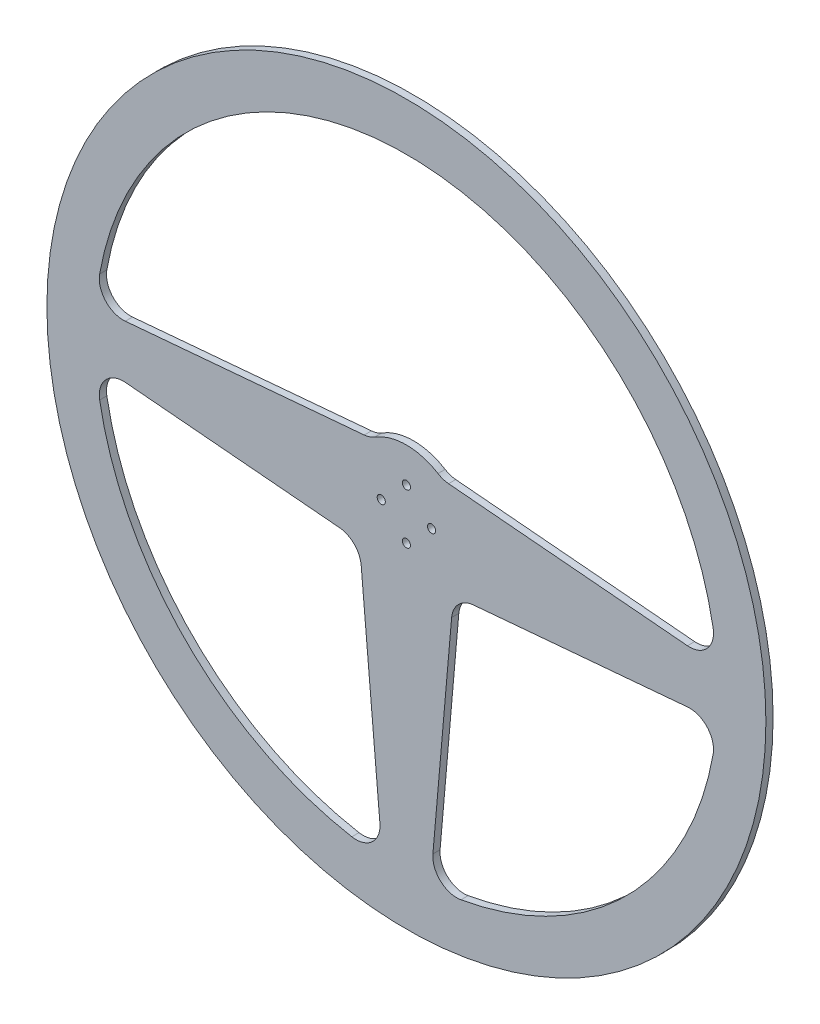
from build123d import *

# Parameters (mm, degrees)
CROQUIS1_R                   = 150
SALIENTE_EXTRUIR1_DEPTH      = 3
REDONDEO1_R                  = 10
TALADRO_DE_MARGEN_PARA_M31_D = 3.4


with BuildPart() as part:
    # Croquis1 → Saliente-Extruir1 (new body)
    with BuildSketch(Plane.XY):
        Circle(CROQUIS1_R)
        with BuildLine():
            Line((9.972316505, -129.616946822), (19.597749078, -19.597749078))
            Line((19.597749078, -19.597749078), (129.616946822, -9.972316505))
            ThreePointArc((129.616946822, -9.972316505), (91.923881554, -91.923881554), (9.972316505, -129.616946822))
        make_face(mode=Mode.SUBTRACT)
        with BuildLine():
            Line((129.616946822, 9.972316505), (15, 20))
            ThreePointArc((15, 20), (0, 25), (-15, 20))
            Line((-15, 20), (-129.616946822, 9.972316505))
            ThreePointArc((-129.616946822, 9.972316505), (0, 130), (129.616946822, 9.972316505))
        make_face(mode=Mode.SUBTRACT)
        with BuildLine():
            Line((-129.616946822, -9.972316505), (-19.597749078, -19.597749078))
            Line((-19.597749078, -19.597749078), (-9.972316505, -129.616946822))
            ThreePointArc((-9.972316505, -129.616946822), (-91.923881554, -91.923881554), (-129.616946822, -9.972316505))
        make_face(mode=Mode.SUBTRACT)
    extrude(amount=SALIENTE_EXTRUIR1_DEPTH)

    # Redondeo1
    redondeo1_edges = [part.edges().sort_by_distance(p)[0] for p in [
        (-129.616946822, 9.972316505, 1.5),
        (-15, 20, 1.5),
        (15, 20, 1.5),
        (129.616946822, 9.972316505, 1.5),
        (9.972316505, -129.616946822, 1.5),
        (129.616946822, -9.972316505, 1.5),
        (19.597749078, -19.597749078, 1.5),
        (-129.616946822, -9.972316505, 1.5),
        (-9.972316505, -129.616946822, 1.5),
        (-19.597749078, -19.597749078, 1.5),
    ]]
    fillet(redondeo1_edges, radius=REDONDEO1_R)

    # Taladro de margen para M31 (through all)
    with Locations(Plane.XY.offset(3)):
        with Locations((0, 10.5), (10.5, 0), (0, -10.5), (-10.5, 0)):
            Hole(TALADRO_DE_MARGEN_PARA_M31_D / 2)


solid = part.part
